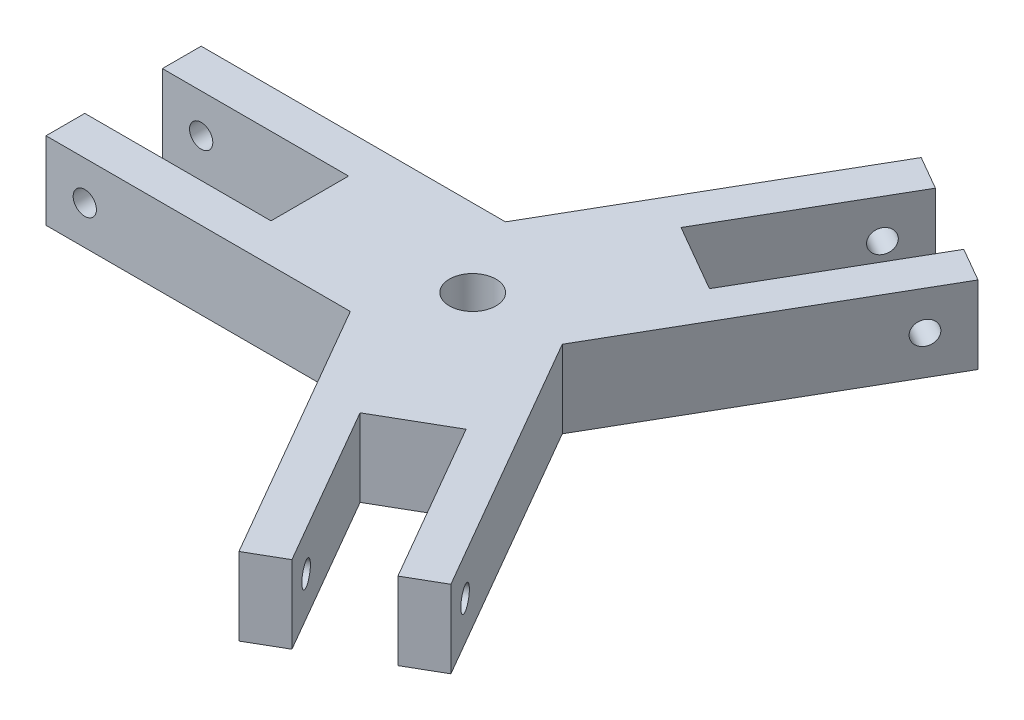
from build123d import *

# Parameters (mm, degrees)
SKETCH1_W          = 45
SKETCH1_H          = 10
MAIN_DEPTH         = 10
SKETCH2_R          = 1.5
CUT_EXTRUDE1_DEPTH = 51.249378106
SKETCH4_W          = 24
SKETCH4_H          = 10
CUT_EXTRUDE3_DEPTH = 48.16990566
CIRPATTERN1_COUNT  = 3
SKETCH3_R          = 3
CUT_EXTRUDE2_DEPTH = 64.706054906


with BuildPart() as part:
    # Sketch1 → Main (new, symmetric)
    with BuildSketch(Plane.XY):
        with Locations((-22.5, 5)):
            Rectangle(SKETCH1_W, SKETCH1_H)
    main = extrude(amount=MAIN_DEPTH, both=True)

    # Sketch2 → Cut-Extrude1 (cut, symmetric)
    with BuildSketch(Plane.XY.offset(10)):
        with Locations((-40, 5)):
            Circle(SKETCH2_R)
    cut_extrude1 = extrude(amount=CUT_EXTRUDE1_DEPTH, both=True, mode=Mode.SUBTRACT)

    # Sketch4 → Cut-Extrude3 (cut, through all)
    with BuildSketch(Plane(origin=(0, 10, 0), x_dir=(1, 0, 0), z_dir=(0, 1, 0))):
        with Locations((-33, 0)):
            Rectangle(SKETCH4_W, SKETCH4_H)
    cut_extrude3 = extrude(amount=-CUT_EXTRUDE3_DEPTH, mode=Mode.SUBTRACT)

    # CirPattern1: Main, Cut-Extrude1, Cut-Extrude3 ×3 about axis
    cirpattern1_axis = Axis((0, -55, 0), (0, 1, 0))
    add([main.rotate(cirpattern1_axis, i * 360 / CIRPATTERN1_COUNT) for i in range(1, CIRPATTERN1_COUNT)])
    add([cut_extrude1.rotate(cirpattern1_axis, i * 360 / CIRPATTERN1_COUNT) for i in range(1, CIRPATTERN1_COUNT)], mode=Mode.SUBTRACT)
    add([cut_extrude3.rotate(cirpattern1_axis, i * 360 / CIRPATTERN1_COUNT) for i in range(1, CIRPATTERN1_COUNT)], mode=Mode.SUBTRACT)

    # Sketch3 → Cut-Extrude2 (cut, through all)
    with BuildSketch(Plane(origin=(0, 10, 0), x_dir=(1, 0, 0), z_dir=(0, 1, 0))):
        Circle(SKETCH3_R)
    extrude(amount=-CUT_EXTRUDE2_DEPTH, mode=Mode.SUBTRACT)


solid = part.part
